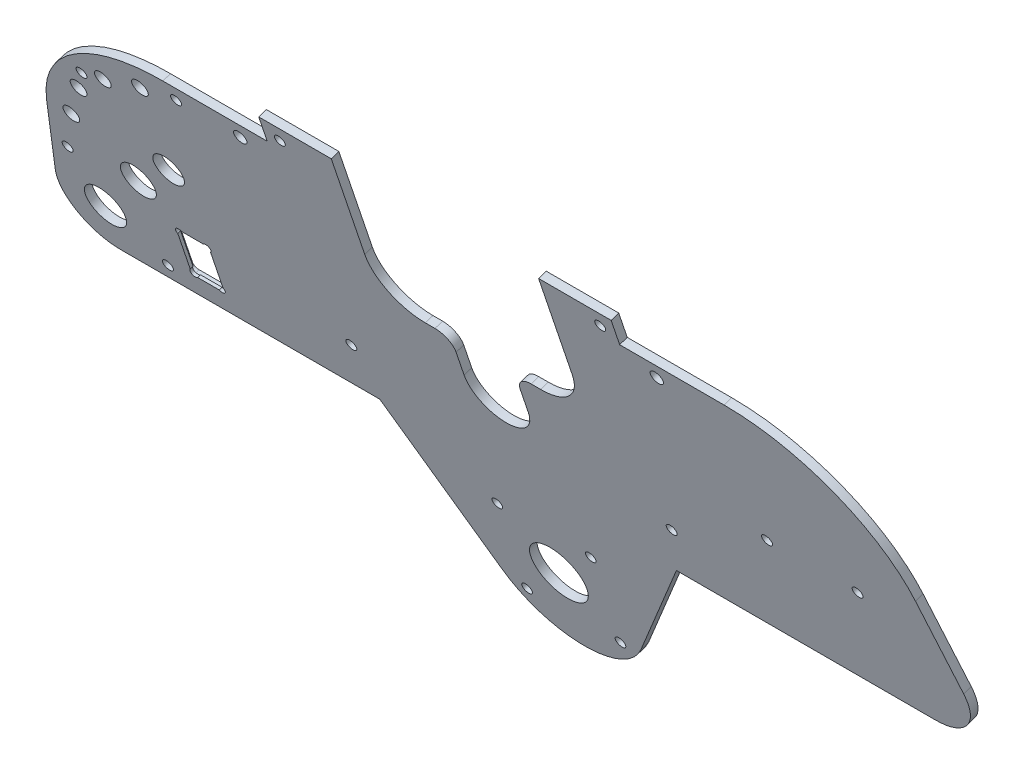
from build123d import *

# Parameters (mm, degrees)
SKETCH1_R               = 11.1125
BOSS_EXTRUDE1_DEPTH     = 3.175
F_1_4_20_TAPPED_HOLE1_D = 5.1054
F_10_32_TAPPED_HOLE1_D  = 4.0386
F_8_32_TAPPED_HOLE1_D   = 4.1656
CUT_EXTRUDE1_DEPTH      = 60.342176846
FILLET1_R               = 19.05
F_8_32_TAPPED_HOLE2_D   = 4.1656
F_10_32_TAPPED_HOLE2_D  = 4.1656
SKETCH14_R              = 3.175
SKETCH14_R_2            = 8
SKETCH14_W              = 13
SKETCH14_H              = 20
CUT_EXTRUDE2_DEPTH      = 57.167176846
CUT_EXTRUDE2_DEPTH_BACK = 60.342176846
CUT_EXTRUDE3_START      = -2
CUT_EXTRUDE3_DEPTH      = 2
SKETCH16_R              = 1.5875
CUT_EXTRUDE4_DEPTH      = 58.342176846


with BuildPart() as part:
    # Sketch1 → Boss-Extrude1 (new body)
    with BuildSketch(Plane(origin=(0, -336.500449063, 1001.043483969), x_dir=(-1, 0, 0), z_dir=(0, 0.318629355, -0.947879388))):
        with BuildLine():
            Line((-58.789402849, 930.579137137), (-27.49630657, 876.377904457))
            ThreePointArc((-27.49630657, 876.377904457), (0, 860.502904457), (27.49630657, 876.377904457))
            Line((27.49630657, 876.377904457), (58.789402849, 930.579137137))
            Line((58.789402849, 930.579137137), (185.147535405, 930.579137137))
            Line((185.147535405, 930.579137137), (172.189234839, 989.158155392))
            add(Edge.make_bspline(
                [(172.189234839, 989.158155392), (170.749787142, 995.665292074), (165.52280255, 1008.174916977), (151.405508558, 1023.513956793), (135.711465445, 1031.867037645), (121.896387082, 1035.290959713), (114.765538474, 1035.868385599), (111.210619201, 1035.868385599)],
                knots=[0.20668663, 0.20668663, 0.20668663, 0.20668663, 0.547714054, 0.888741478, 1.229768903, 1.400282615, 1.570796327, 1.570796327, 1.570796327, 1.570796327], degree=3))
            Line((111.210619201, 1035.868385599), (69.85, 1035.868385599))
            Line((69.85, 1035.868385599), (69.85, 1046.47326385))
            Line((69.85, 1046.47326385), (-69.85, 1046.47326385))
            Line((-69.85, 1046.47326385), (-69.85, 1035.868385599))
            Line((-69.85, 1035.868385599), (-111.210619201, 1035.868385599))
            add(Edge.make_bspline(
                [(-172.189234839, 989.158155392), (-170.749787142, 995.665292074), (-165.52280255, 1008.174916977), (-151.405508558, 1023.513956793), (-135.711465445, 1031.867037645), (-121.896387082, 1035.290959713), (-114.765538474, 1035.868385599), (-111.210619201, 1035.868385599)],
                knots=[0.20668663, 0.20668663, 0.20668663, 0.20668663, 0.547714054, 0.888741478, 1.229768903, 1.400282615, 1.570796327, 1.570796327, 1.570796327, 1.570796327], degree=3))
            Line((-172.189234839, 989.158155392), (-185.147535405, 930.579137137))
            Line((-185.147535405, 930.579137137), (-58.789402849, 930.579137137))
        make_face()
        with Locations((0, 892.252904457)):
            Circle(SKETCH1_R, mode=Mode.SUBTRACT)
    extrude(amount=BOSS_EXTRUDE1_DEPTH)

    # 1/4-20 Tapped Hole1 (through all)
    with Locations(Plane(origin=(0, -335.48880086, 998.033966912), x_dir=(-1, 0, 0), z_dir=(0, 0.318629355, -0.947879388))):
        with Locations((82.55, 1029.518385599), (-82.55, 1029.518385599)):
            Hole(F_1_4_20_TAPPED_HOLE1_D / 2)

    # #10-32 Tapped Hole1 (through all)
    with Locations(Plane(origin=(0, -335.48880086, 998.033966912), x_dir=(-1, 0, 0), z_dir=(0, 0.318629355, -0.947879388))):
        with Locations((-18.52177825, 873.731126207), (18.52177825, 873.731126207), (18.52177825, 910.774682707), (-18.52177825, 910.774682707)):
            Hole(F_10_32_TAPPED_HOLE1_D / 2)

    # #8-32 Tapped Hole1 (through all)
    with Locations(Plane(origin=(0, -336.500449063, 1001.043483969), x_dir=(1, 0, 0), z_dir=(0, -0.318629355, 0.947879388))):
        with Locations((63.5, 1040.12326385), (63.5, 951.22326385), (-63.5, 951.22326385), (-63.5, 1040.12326385)):
            Hole(F_8_32_TAPPED_HOLE1_D / 2)

    # Sketch8 → Cut-Extrude1 (cut, through all)
    with BuildSketch(Plane(origin=(0, -335.48880086, 998.033966912), x_dir=(-1, 0, 0), z_dir=(0, 0.318629355, -0.947879388))):
        with BuildLine():
            Line((-41.090457195, 1046.47326385), (-41.090457195, 1004.8172638))
            ThreePointArc((-41.090457195, 1004.8172638), (-35.750879913, 991.926383908), (-22.860000021, 986.586806626))
            Line((-22.860000021, 986.586806626), (-19.05, 986.586806627))
            ThreePointArc((-19.05, 986.586806627), (-14.55987194, 984.726934687), (-12.7, 980.236806627))
            Line((-12.7, 980.236806627), (-12.7, 970.27326385))
            ThreePointArc((-12.7, 970.27326385), (0, 957.57326385), (12.7, 970.27326385))
            Line((12.7, 970.27326385), (12.7, 980.236806629))
            ThreePointArc((12.7, 980.236806629), (14.559871939, 984.726934689), (19.05, 986.586806629))
            Line((19.05, 986.586806629), (22.860000023, 986.586806629))
            ThreePointArc((22.860000023, 986.586806629), (35.75087992, 991.926383918), (41.090457195, 1004.817263822))
            Line((41.090457195, 1004.817263822), (41.0904572, 1046.47326385))
            Line((41.0904572, 1046.47326385), (-41.090457195, 1046.47326385))
        make_face()
    extrude(amount=-CUT_EXTRUDE1_DEPTH, mode=Mode.SUBTRACT)

    # Fillet1
    fillet1_edges = [part.edges().sort_by_distance(p)[0] for p in [
        (-185.147535405, 546.082157979, 1296.048555754),
        (185.147535405, 546.082157979, 1296.048555754),
    ]]
    fillet(fillet1_edges, radius=FILLET1_R)

    # #8-32 Tapped Hole2 (through all)
    with Locations(Plane(origin=(0, -335.48880086, 998.033966912), x_dir=(-1, 0, 0), z_dir=(0, 0.318629355, -0.947879388))):
        with Locations((140.734737002, 936.929137137), (169.906145104, 970.079411683), (150.197707432, 1014.705385734), (107.992809601, 1029.518385599)):
            Hole(F_8_32_TAPPED_HOLE2_D / 2)

    # #10-32 Tapped Hole2 (through all)
    with Locations(Plane(origin=(0, -335.48880086, 998.033966912), x_dir=(-1, 0, 0), z_dir=(0, 0.318629355, -0.947879388))):
        with Locations((-109.05, 975.579137137), (-144.95, 975.579137137)):
            Hole(F_10_32_TAPPED_HOLE2_D / 2)

    # Sketch14 → Cut-Extrude2 (cut, two sides)
    with BuildSketch(Plane(origin=(0, -335.48880086, 998.033966912), x_dir=(-1, 0, 0), z_dir=(0, 0.318629355, -0.947879388))) as cut_extrude2_sk:
        with Locations((123.809674977, 1024.920248146)):
            Circle(SKETCH14_R)
        with Locations((140.734737002, 1017.918189485)):
            Circle(SKETCH14_R)
        with Locations((154.272103769, 1005.5801892)):
            Circle(SKETCH14_R)
        with Locations((162.384030522, 989.158155392)):
            Circle(SKETCH14_R)
        with Locations((161.422942212, 949.629137137)):
            Circle(SKETCH14_R_2)
        with Locations((123.809674977, 949.629137137)):
            Rectangle(SKETCH14_W, SKETCH14_H)
        with BuildLine():
            ThreePointArc((145.026756344, 968.449444325), (140.734737002, 980.539444325), (136.44271766, 968.449444325))
            ThreePointArc((136.44271766, 968.449444325), (140.734737002, 966.925752842), (145.026756344, 968.449444325))
        make_face()
        with BuildLine():
            ThreePointArc((126.779520488, 983.951155392), (123.809674977, 995.152555392), (120.839829466, 983.951155392))
            ThreePointArc((120.839829466, 983.951155392), (123.809674977, 983.163755392), (126.779520488, 983.951155392))
        make_face()
    extrude(amount=CUT_EXTRUDE2_DEPTH, mode=Mode.SUBTRACT)
    extrude(cut_extrude2_sk.sketch, amount=-CUT_EXTRUDE2_DEPTH_BACK, mode=Mode.SUBTRACT)

    # Sketch15 → Cut-Extrude3 (cut)
    with BuildSketch(Plane(origin=(0, -335.48880086, 998.033966912), x_dir=(-1, 0, 0), z_dir=(0, 0.318629355, -0.947879388)).offset(CUT_EXTRUDE3_START)):
        with BuildLine():
            Line((131.059674977, 962.450565709), (116.559674977, 962.450565709))
            ThreePointArc((116.559674977, 962.450565709), (115.145461415, 961.864779271), (114.559674977, 960.450565709))
            Line((114.559674977, 960.450565709), (114.559674977, 939.950565709))
            ThreePointArc((114.559674977, 939.950565709), (115.145461415, 938.536352147), (116.559674977, 937.950565709))
            Line((116.559674977, 937.950565709), (131.059674977, 937.950565709))
            ThreePointArc((131.059674977, 937.950565709), (132.473888539, 938.536352147), (133.059674977, 939.950565709))
            Line((133.059674977, 939.950565709), (133.059674977, 960.450565709))
            ThreePointArc((133.059674977, 960.450565709), (132.473888539, 961.864779271), (131.059674977, 962.450565709))
        make_face()
    extrude(amount=CUT_EXTRUDE3_DEPTH, mode=Mode.SUBTRACT)

    # Sketch16 → Cut-Extrude4 (cut, through all)
    with BuildSketch(Plane(origin=(0, -336.126059571, 999.929725688), x_dir=(-1, 0, 0), z_dir=(0, 0.318629355, -0.947879388))):
        with Locations((118.432206992, 958.506605122)):
            Circle(SKETCH16_R)
        with Locations((129.187142962, 958.506605122)):
            Circle(SKETCH16_R)
        with Locations((129.187142962, 940.751669153)):
            Circle(SKETCH16_R)
        with Locations((118.432206992, 940.751669153)):
            Circle(SKETCH16_R)
    extrude(amount=-CUT_EXTRUDE4_DEPTH, mode=Mode.SUBTRACT)


solid = part.part
